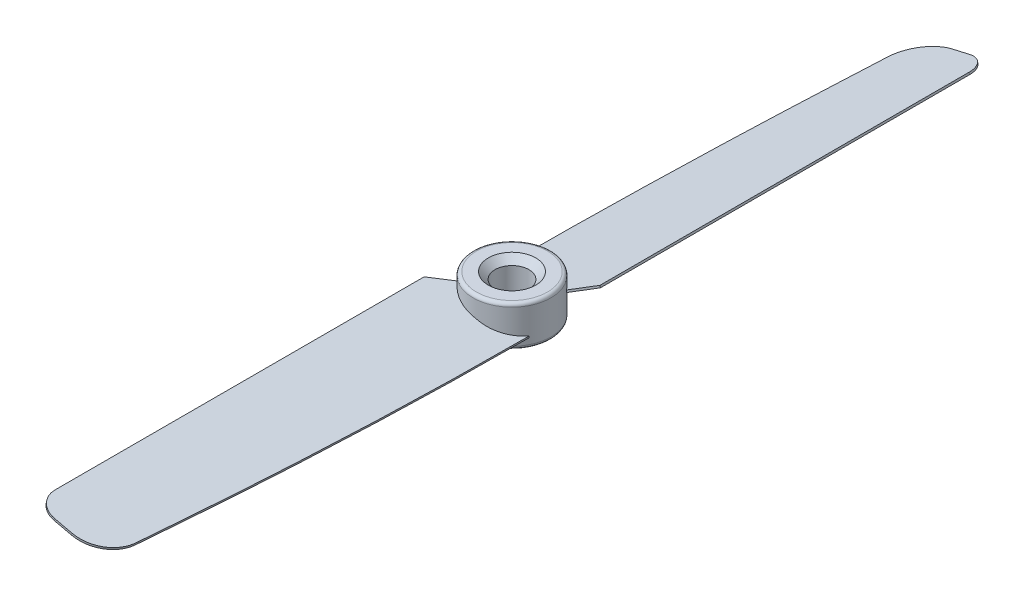
from build123d import *

# Parameters (mm, degrees)
SKETCH1_R           = 5.75
BOSS_EXTRUDE1_DEPTH = 3
BOSS_EXTRUDE2_DEPTH = 0.15
CIRPATTERN1_COUNT   = 2
SKETCH4_R           = 2.5
CUT_EXTRUDE1_DEPTH  = 7.0000001
FILLET1_R           = 0.5
CHAMFER1_SIZE       = 1


with BuildPart() as part:
    # Sketch1 → Boss-Extrude1 (new body, symmetric)
    with BuildSketch(Plane(origin=(0, 0, 0), x_dir=(1, 0, 0), z_dir=(0, 1, 0))):
        Circle(SKETCH1_R)
    extrude(amount=BOSS_EXTRUDE1_DEPTH, both=True)

    # Sketch3 → Boss-Extrude2 (add, symmetric)
    with BuildSketch(Plane(origin=(0, 0, 0), x_dir=(0.974370065, -0.224951054, 0), z_dir=(-0.224951054, -0.974370065, 0))):
        with BuildLine():
            Line((-7.260028368, 5.954486728), (-4.178380211, 2.872838571))
            add(Edge.make_bspline(
                [(0.674853163, 5.75), (-2.561446771, 5.75), (-4.178380211, 2.872838571)],
                knots=[0, 0, 0, 1.04763155, 1.04763155, 1.04763155], degree=2, weights=[1, 0.865916884, 1]))
            add(Edge.make_bspline(
                [(5.528086537, 2.872838571), (3.911153097, 5.75), (0.674853163, 5.75)],
                knots=[5.235553758, 5.235553758, 5.235553758, 6.283185307, 6.283185307, 6.283185307], degree=2, weights=[1, 0.865916884, 1]))
            add(Edge.make_bspline(
                [(5.528086537, 2.872838571), (5.499674649, 33.834937196), (3.406999963, 56.967753658), (3.396685559, 58.53294855)],
                knots=[0, 0, 0, 0, 0.918193758, 0.918193758, 0.918193758, 0.918193758], degree=3))
            ThreePointArc((3.396685559, 58.53294855), (1.920659701, 62.047163849), (-1.603205879, 63.5))
            Line((-1.603205879, 63.5), (-4.260028368, 63.5))
            ThreePointArc((-4.260028368, 63.5), (-6.381348711, 62.621320344), (-7.260028368, 60.5))
            Line((-7.260028368, 60.5), (-7.260028368, 5.954486728))
        make_face()
    boss_extrude2 = extrude(amount=BOSS_EXTRUDE2_DEPTH, both=True)

    # CirPattern1: Boss-Extrude2 ×2 about axis
    cirpattern1_axis = Axis((0, 3, 0), (0, -1, 0))
    for i in range(1, CIRPATTERN1_COUNT):
        add(boss_extrude2.rotate(cirpattern1_axis, i * 360 / CIRPATTERN1_COUNT))

    # Sketch4 → Cut-Extrude1 (cut, through all)
    with BuildSketch(Plane.XZ.offset(3)):
        Circle(SKETCH4_R)
    extrude(amount=-CUT_EXTRUDE1_DEPTH, mode=Mode.SUBTRACT)

    # Fillet1
    fillet1_edges = [part.edges().sort_by_distance(p)[0] for p in [
        (-5.75, -3, 0),
        (-5.75, 3, 0),
    ]]
    fillet(fillet1_edges, radius=FILLET1_R)

    # Chamfer1
    chamfer1_edges = [part.edges().sort_by_distance(p)[0] for p in [
        (-2.5, 3, 0),
        (-2.5, -3, 0),
    ]]
    chamfer(chamfer1_edges, length=CHAMFER1_SIZE)


solid = part.part
